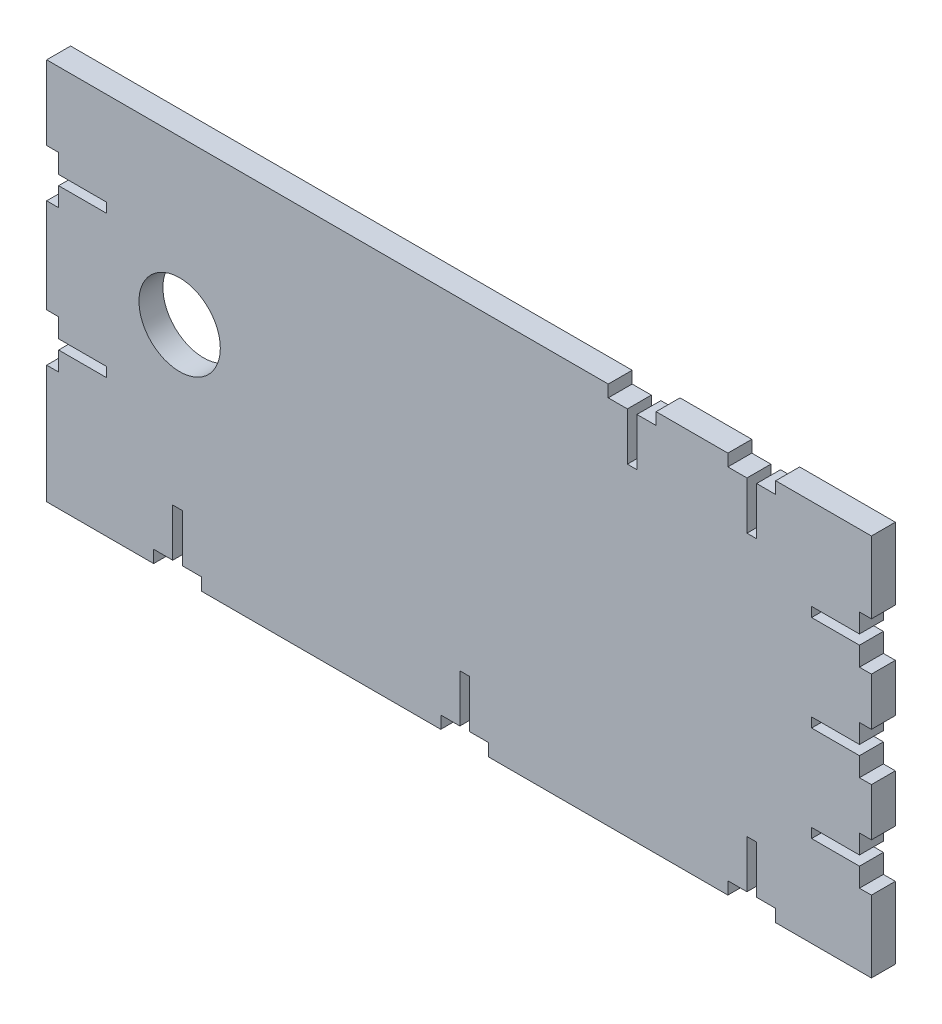
from build123d import *

# Parameters (mm, degrees)
BOSS_EXTRUDE1_DEPTH     = 6.35
CUT_EXTRUDE4_DEPTH      = 127
CUT_EXTRUDE4_DEPTH_BACK = 127
CUT_EXTRUDE5_DEPTH      = 127
CUT_EXTRUDE5_DEPTH_BACK = 127
CUT_EXTRUDE7_DEPTH      = 127
CUT_EXTRUDE7_DEPTH_BACK = 127
SKETCH5_W               = 229.808362084
SKETCH5_H               = 77.917038349
CUT_EXTRUDE8_DEPTH      = 127
CUT_EXTRUDE8_DEPTH_BACK = 127
SKETCH6_R               = 10.795


with BuildPart() as part:
    # Sketch1 → Boss-Extrude1 (new body)
    with BuildSketch(Plane.XY):
        Polygon((0, 0), (127, 0), (127, 101.6), (0, 101.6), (-70.692427737, 172.292427737), (-91.896861793, 151.087993682), (-91.896861793, 0), align=None)
    extrude(amount=BOSS_EXTRUDE1_DEPTH)

    # Sketch3 → Cut-Extrude4 (cut, two sides: drawn at the far end of the back side and taken through both)
    with BuildSketch(Plane(origin=(0, 0, 0), x_dir=(-1, 0, 0), z_dir=(0, 0, -1)).offset(-CUT_EXTRUDE4_DEPTH_BACK)):
        Polygon((68.447363707, 161.067107586), (63.957235647, 156.576979525), (66.202299677, 154.331915495), (70.692427737, 158.822043556), align=None)
        Polygon((-127, 31.75), (-127, 19.05), (-123.825, 19.05), (-123.825, 24.1173), (-111.125, 24.1173), (-111.125, 26.6827), (-123.825, 26.6827), (-123.825, 31.75), align=None)
        Polygon((-57.15, 101.6), (-69.85, 101.6), (-69.85, 98.425), (-64.77, 98.425), (-64.77, 85.725), (-62.23, 85.725), (-62.23, 98.425), (-57.15, 98.425), align=None)
        Polygon((-88.9, 101.6), (-101.6, 101.6), (-101.6, 98.425), (-96.5327, 98.425), (-96.5327, 85.725), (-93.9673, 85.725), (-93.9673, 98.425), (-88.9, 98.425), align=None)
        Polygon((-127, 82.55), (-127, 69.85), (-123.825, 69.85), (-123.825, 74.9173), (-111.125, 74.9173), (-111.125, 77.4827), (-123.825, 77.4827), (-123.825, 82.55), align=None)
        Polygon((-127, 57.15), (-127, 44.45), (-123.825, 44.45), (-123.825, 49.5173), (-111.125, 49.5173), (-111.125, 52.0827), (-123.825, 52.0827), (-123.825, 57.15), align=None)
        Polygon((88.721861793, 106.965995261), (91.896861793, 106.965995261), (91.896861793, 119.665995261), (88.721861793, 119.665995261), (88.721861793, 114.598695261), (76.021861793, 114.598695261), (76.021861793, 112.033295261), (88.721861793, 112.033295261), align=None)
        Polygon((88.721861793, 69.193996841), (91.896861793, 69.193996841), (91.896861793, 81.893996841), (88.721861793, 81.893996841), (88.721861793, 76.826696841), (76.021861793, 76.826696841), (76.021861793, 74.261296841), (88.721861793, 74.261296841), align=None)
        Polygon((88.721861793, 31.42199842), (91.896861793, 31.42199842), (91.896861793, 44.12199842), (88.721861793, 44.12199842), (88.721861793, 39.05469842), (76.021861793, 39.05469842), (76.021861793, 36.48929842), (88.721861793, 36.48929842), align=None)
        Polygon((50.8, 3.302), (50.8, 0), (63.5, 0), (63.5, 3.302), (58.4327, 3.302), (58.4327, 16.002), (55.8673, 16.002), (55.8673, 3.302), align=None)
        Polygon((-25.4, 3.302), (-25.4, 0), (-12.7, 0), (-12.7, 3.302), (-17.7673, 3.302), (-17.7673, 16.002), (-20.3327, 16.002), (-20.3327, 3.302), align=None)
        Polygon((-101.6, 3.302), (-101.6, 0), (-88.9, 0), (-88.9, 3.302), (-93.9673, 3.302), (-93.9673, 16.002), (-96.5327, 16.002), (-96.5327, 3.302), align=None)
    extrude(amount=CUT_EXTRUDE4_DEPTH + CUT_EXTRUDE4_DEPTH_BACK, mode=Mode.SUBTRACT)

    # Sketch4 → Cut-Extrude5 (cut, two sides: drawn at the far end of the back side and taken through both)
    with BuildSketch(Plane.XY.offset(-CUT_EXTRUDE5_DEPTH_BACK)):
        Polygon((-81.917747889, 147.596723404), (-79.672683858, 149.841787435), (-75.182555798, 145.351659374), (-77.427619828, 143.106595344), align=None)
    extrude(amount=CUT_EXTRUDE5_DEPTH + CUT_EXTRUDE5_DEPTH_BACK, mode=Mode.SUBTRACT)

    # Sketch5 → Cut-Extrude7 (cut, two sides: drawn at the far end of the back side and taken through both)
    with BuildSketch(Plane.XY.offset(-CUT_EXTRUDE7_DEPTH_BACK)):
        with Locations((12.095818958, 140.558519175)):
            Rectangle(SKETCH5_W, SKETCH5_H)
    extrude(amount=CUT_EXTRUDE7_DEPTH + CUT_EXTRUDE7_DEPTH_BACK, mode=Mode.SUBTRACT)

    # Sketch6 → Cut-Extrude8 (cut, two sides: drawn at the far end of the back side and taken through both)
    with BuildSketch(Plane(origin=(0, 0, -2.54), x_dir=(-1, 0, 0), z_dir=(0, 0, -1)).offset(-CUT_EXTRUDE8_DEPTH_BACK)):
        with Locations((56.601909208, 58.354277065)):
            Circle(SKETCH6_R)
    extrude(amount=CUT_EXTRUDE8_DEPTH + CUT_EXTRUDE8_DEPTH_BACK, mode=Mode.SUBTRACT)


solid = part.part
